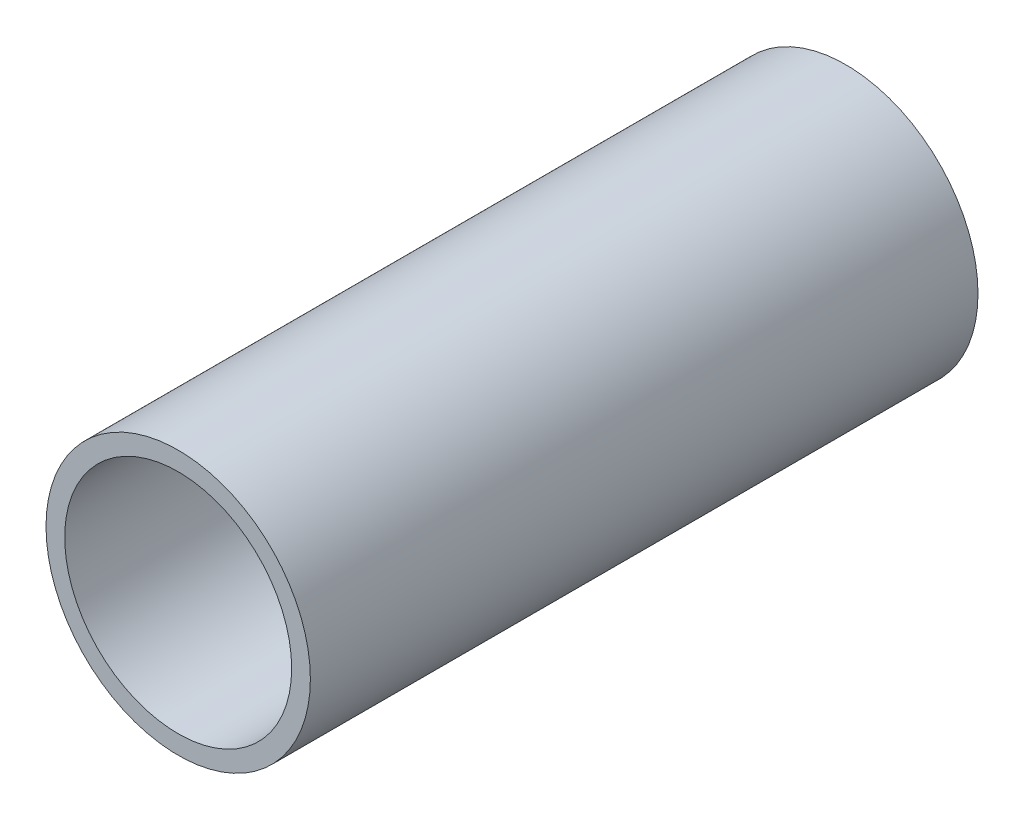
from build123d import *

# Parameters (mm, degrees)
SKETCH1_R           = 12.573
SKETCH1_R_2         = 10.795
BOSS_EXTRUDE1_DEPTH = 63.5


with BuildPart() as part:
    # Sketch1 → Boss-Extrude1 (new body)
    with BuildSketch(Plane.XY):
        Circle(SKETCH1_R)
        Circle(SKETCH1_R_2, mode=Mode.SUBTRACT)
    extrude(amount=BOSS_EXTRUDE1_DEPTH)


solid = part.part
